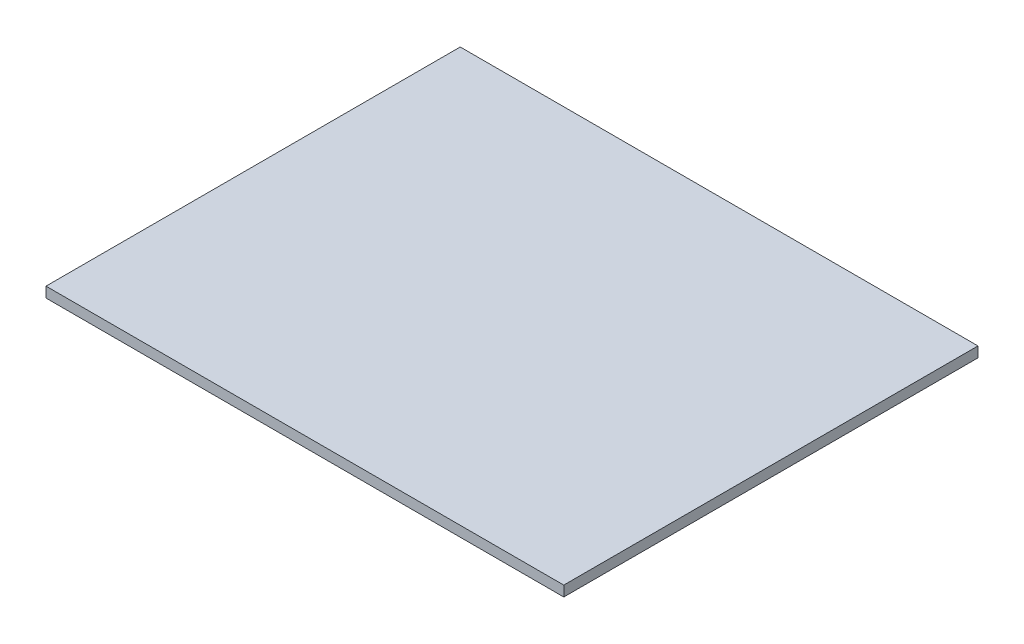
from build123d import *

# Parameters (mm, degrees)
SKETCH_1_W      = 150
SKETCH_1_H      = 120
EXTRUDE_1_DEPTH = 3


with BuildPart() as part:
    # 草图1 → 凸台-拉伸1 (new body)
    with BuildSketch(Plane(origin=(0, 0, 0), x_dir=(1, 0, 0), z_dir=(0, 1, 0))):
        with Locations((75, -60)):
            Rectangle(SKETCH_1_W, SKETCH_1_H)
    extrude(amount=EXTRUDE_1_DEPTH)


solid = part.part
